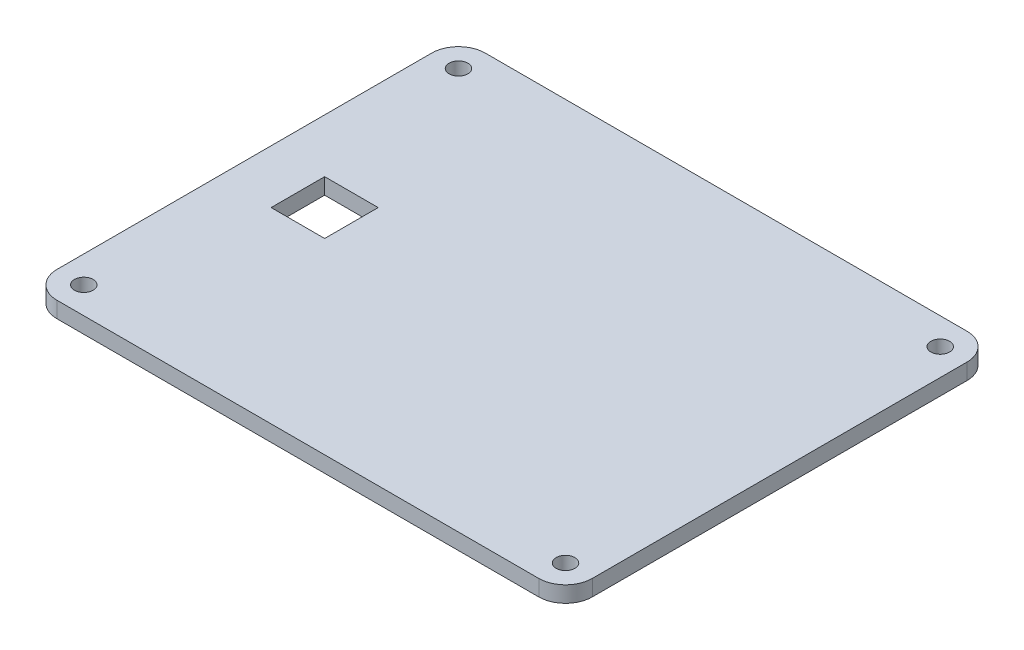
from build123d import *

# Parameters (mm, degrees)
BOSS_EXTRUDE1_DEPTH  = 3
SKETCH3_R            = 1.75
CUT_EXTRUDE2_DEPTH   = 4
LPATTERN1_COUNT      = 2
LPATTERN1_PITCH      = 70
LPATTERN1_COUNT_DIR2 = 2
LPATTERN1_PITCH_DIR2 = 90
SKETCH5_W            = 10
SKETCH5_H            = 10
CUT_EXTRUDE4_DEPTH   = 4


with BuildPart() as part:
    # Sketch1 → Boss-Extrude1 (new body)
    with BuildSketch(Plane(origin=(0, 0, 0), x_dir=(1, 0, 0), z_dir=(0, 1, 0))):
        with BuildLine():
            Line((-45, 40), (45, 40))
            ThreePointArc((45, 40), (48.535533906, 38.535533906), (50, 35))
            Line((50, 35), (50, -35))
            ThreePointArc((50, -35), (48.535533906, -38.535533906), (45, -40))
            Line((45, -40), (-45, -40))
            ThreePointArc((-45, -40), (-48.535533906, -38.535533906), (-50, -35))
            Line((-50, -35), (-50, 35))
            ThreePointArc((-50, 35), (-48.535533906, 38.535533906), (-45, 40))
        make_face()
    extrude(amount=BOSS_EXTRUDE1_DEPTH)

    # Sketch3 → Cut-Extrude2 (cut, through all)
    with BuildSketch(Plane(origin=(0, 3, 0), x_dir=(1, 0, 0), z_dir=(0, 1, 0))):
        with Locations((-45, -35)):
            Circle(SKETCH3_R)
    cut_extrude2 = extrude(amount=-CUT_EXTRUDE2_DEPTH, mode=Mode.SUBTRACT)

    # LPattern1: Cut-Extrude2 2 × 2
    with Locations(*[(j * LPATTERN1_PITCH_DIR2, 0, -i * LPATTERN1_PITCH) for i in range(LPATTERN1_COUNT) for j in range(LPATTERN1_COUNT_DIR2) if (i, j) != (0, 0)]):
        add(cut_extrude2, mode=Mode.SUBTRACT)

    # Sketch5 → Cut-Extrude4 (cut, through all)
    with BuildSketch(Plane(origin=(0, 3, 0), x_dir=(1, 0, 0), z_dir=(0, 1, 0))):
        with Locations((-35, 0)):
            Rectangle(SKETCH5_W, SKETCH5_H)
    extrude(amount=-CUT_EXTRUDE4_DEPTH, mode=Mode.SUBTRACT)


solid = part.part
